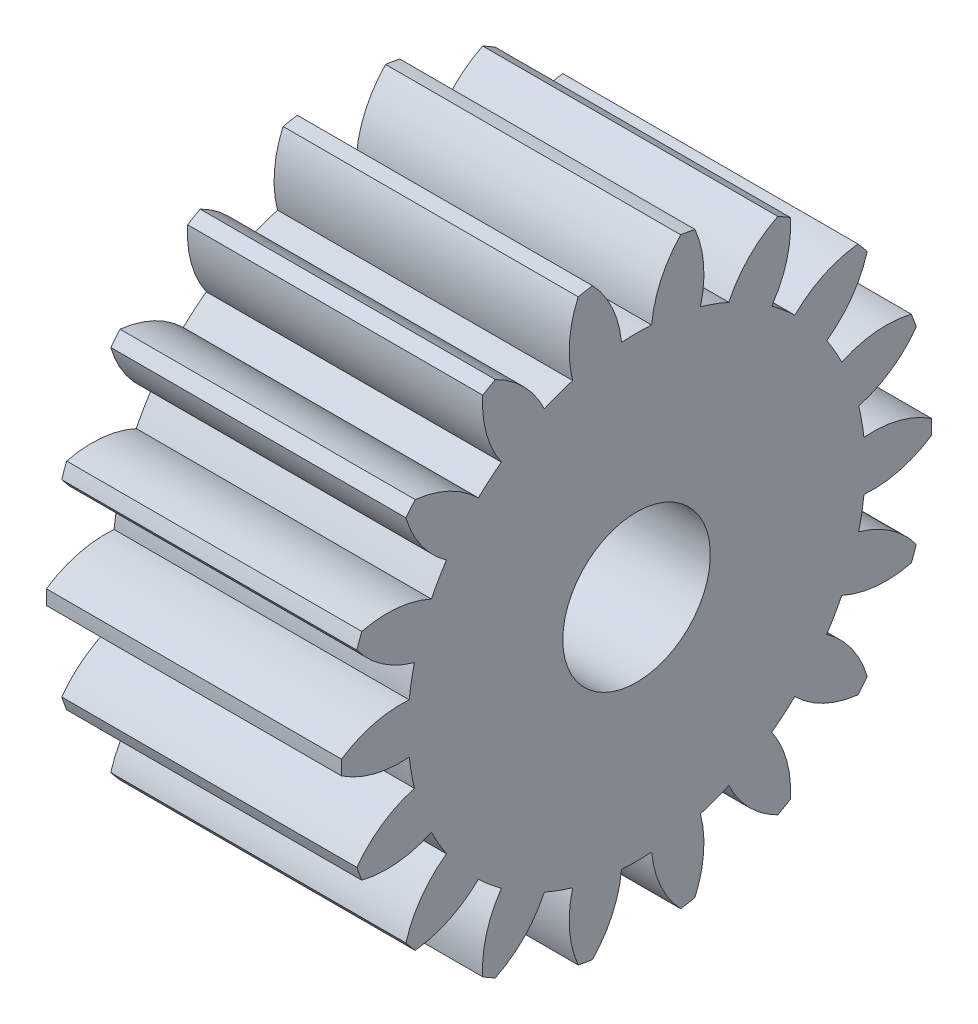
from build123d import *

# Parameters (mm, degrees)
BASPROSKE_W     = 10
BASPROSKE_H     = 10
TOOTHCUT_DEPTH  = 18.320508076
TEETHCUTS_COUNT = 18
TEETHCUTS_ANGLE = 340
BORSKE_R        = 2.5
BORE_DEPTH      = 50.0000508


with BuildPart() as part:
    # BasProSke → Base-Revolve (revolve)
    with BuildSketch(Plane(origin=(0, 0, 0), x_dir=(1, 0, 0), z_dir=(0, 1, 0)), mode=Mode.PRIVATE) as base_revolve_sk:
        with Locations((5, 5)):
            Rectangle(BASPROSKE_W, BASPROSKE_H)
    revolve(base_revolve_sk.sketch.rotate(Axis((-10, 0, 0), (1, 0, 0)), 180), axis=Axis((-10, 0, 0), (1, 0, 0)))

    # TooCutSke → ToothCut (cut, through all)
    with BuildSketch(Plane(origin=(0, 0, 0), x_dir=(0, 0, -1), z_dir=(1, 0, 0))):
        with BuildLine():
            ThreePointArc((0.510641536, 7.732156635), (0, 7.749), (-0.510641536, 7.732156635))
            ThreePointArc((-0.510641536, 7.732156635), (-0.82619259, 8.907320741), (-1.515208602, 9.910236529))
            ThreePointArc((-1.515208602, 9.910236529), (0, 10.0254), (1.515208602, 9.910236529))
            ThreePointArc((1.515208602, 9.910236529), (0.82619259, 8.907320741), (0.510641536, 7.732156635))
        make_face()
    toothcut = extrude(amount=TOOTHCUT_DEPTH, mode=Mode.SUBTRACT)

    # TeethCuts: ToothCut ×18 about axis
    teethcuts_axis = Axis((-10, 0, 0), (1, 0, 0))
    for i in range(1, TEETHCUTS_COUNT):
        add(toothcut.rotate(teethcuts_axis, i * TEETHCUTS_ANGLE / (TEETHCUTS_COUNT - 1)), mode=Mode.SUBTRACT)

    # BorSke → Bore (cut, symmetric)
    with BuildSketch(Plane(origin=(0, 0, 0), x_dir=(0, 0, -1), z_dir=(1, 0, 0))):
        with Locations(Location((0, 0, 0), (0, 0, 180))):
            Circle(BORSKE_R)
    extrude(amount=BORE_DEPTH, both=True, mode=Mode.SUBTRACT)


solid = part.part
